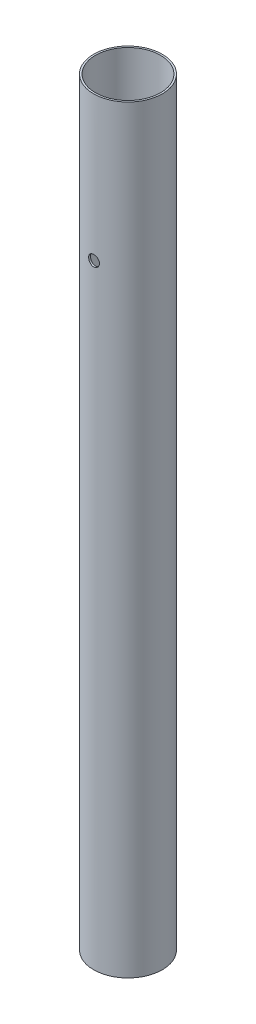
from build123d import *

# Parameters (mm, degrees)
SKETCH1_R               = 9.5
SKETCH1_R_2             = 9
BOSS_EXTRUDE1_DEPTH     = 210
SKETCH2_R               = 1.5
CUT_EXTRUDE1_DEPTH      = 10.5
CUT_EXTRUDE1_DEPTH_BACK = 10.5


with BuildPart() as part:
    # Sketch1 → Boss-Extrude1 (new body)
    with BuildSketch(Plane(origin=(0, 0, 0), x_dir=(1, 0, 0), z_dir=(0, 1, 0))):
        Circle(SKETCH1_R)
        Circle(SKETCH1_R_2, mode=Mode.SUBTRACT)
    extrude(amount=BOSS_EXTRUDE1_DEPTH)

    # Sketch2 → Cut-Extrude1 (cut, two sides)
    with BuildSketch(Plane.XY) as cut_extrude1_sk:
        with Locations((0, 170)):
            Circle(SKETCH2_R)
    extrude(amount=CUT_EXTRUDE1_DEPTH, mode=Mode.SUBTRACT)
    extrude(cut_extrude1_sk.sketch, amount=-CUT_EXTRUDE1_DEPTH_BACK, mode=Mode.SUBTRACT)


solid = part.part
